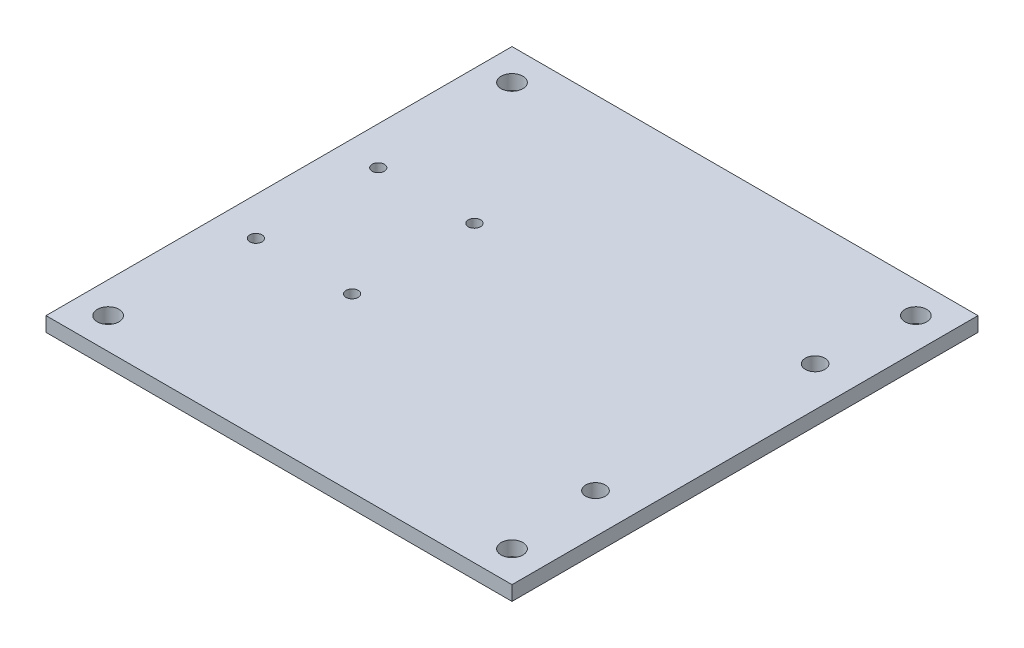
from build123d import *

# Parameters (mm, degrees)
SKETCH2_W           = 152.4
SKETCH2_H           = 152.4
SKETCH2_R           = 3.2004
SKETCH2_R_2         = 3.556
SKETCH2_R_3         = 2
BOSS_EXTRUDE1_DEPTH = 4.7625


with BuildPart() as part:
    # Sketch2 → Boss-Extrude1 (new body)
    with BuildSketch(Plane(origin=(0, 0, 0), x_dir=(1, 0, 0), z_dir=(0, 1, 0))):
        with Locations((76.2, 50.8)):
            Rectangle(SKETCH2_W, SKETCH2_H)
        with Locations((139.419367389, 14.8828125)):
            Circle(SKETCH2_R, mode=Mode.SUBTRACT)
        with Locations((139.419367389, 86.7171875)):
            Circle(SKETCH2_R, mode=Mode.SUBTRACT)
        with Locations((142.24, 116.84)):
            Circle(SKETCH2_R_2, mode=Mode.SUBTRACT)
        with Locations((10.16, 116.84)):
            Circle(SKETCH2_R_2, mode=Mode.SUBTRACT)
        with Locations((10.16, -15.24)):
            Circle(SKETCH2_R_2, mode=Mode.SUBTRACT)
        with Locations((142.24, -15.24)):
            Circle(SKETCH2_R_2, mode=Mode.SUBTRACT)
        with Locations((12.451545477, 30.80004)):
            Circle(SKETCH2_R_3, mode=Mode.SUBTRACT)
        with Locations((43.904269028, 30.80004)):
            Circle(SKETCH2_R_3, mode=Mode.SUBTRACT)
        with Locations((43.904269028, 70.79996)):
            Circle(SKETCH2_R_3, mode=Mode.SUBTRACT)
        with Locations((12.451545477, 70.79996)):
            Circle(SKETCH2_R_3, mode=Mode.SUBTRACT)
    extrude(amount=BOSS_EXTRUDE1_DEPTH)


solid = part.part
